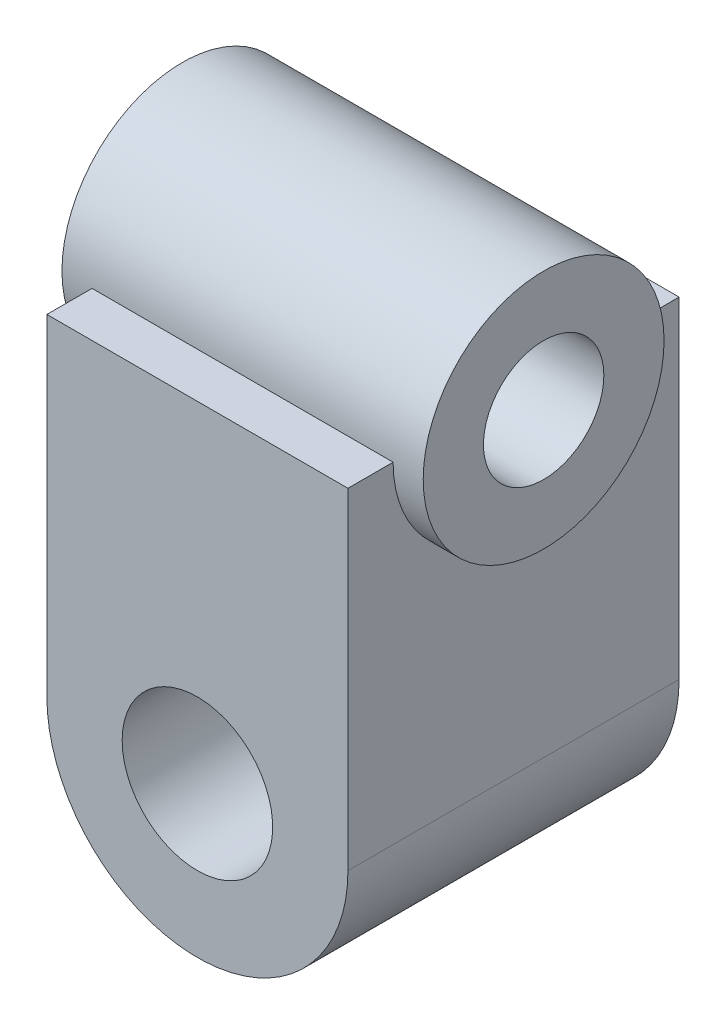
from build123d import *

# Parameters (mm, degrees)
SKETCH1_R                  = 31.75
BOSS_EXTRUDE1_DEPTH        = 34.925
SKETCH3_R                  = 25.4
BOSS_EXTRUDE2_DEPTH        = 38.1
F_97_1_DIAMETER_HOLE1_D    = 25.4
F_97_1_25_DIAMETER_HOLE1_D = 31.75


with BuildPart() as part:
    # Sketch1 → Boss-Extrude1 (new body, symmetric)
    with BuildSketch(Plane.XY):
        with BuildLine():
            ThreePointArc((-31.75, 0), (0, 31.75), (31.75, 0))
            Line((31.75, 0), (31.75, 69.85))
            Line((31.75, 69.85), (-31.75, 69.85))
            Line((-31.75, 69.85), (-31.75, 0))
        make_face()
        Circle(SKETCH1_R)
    extrude(amount=BOSS_EXTRUDE1_DEPTH, both=True)

    # Sketch3 → Boss-Extrude2 (add, symmetric)
    with BuildSketch(Plane(origin=(0, 0, 0), x_dir=(0, 0, -1), z_dir=(1, 0, 0))):
        with Locations((0, 69.85)):
            Circle(SKETCH3_R)
    extrude(amount=BOSS_EXTRUDE2_DEPTH, both=True)

    # #97 (1) Diameter Hole1 (through all)
    with Locations(Plane(origin=(38.1, 0, 0), x_dir=(0, 0, -1), z_dir=(1, 0, 0))):
        with Locations((0, 69.85)):
            Hole(F_97_1_DIAMETER_HOLE1_D / 2)

    # #97 (1.25) Diameter Hole1 (through all)
    with Locations(Plane(origin=(0, 0, -34.925), x_dir=(-1, 0, 0), z_dir=(0, 0, -1))):
        with Locations((0, 0)):
            Hole(F_97_1_25_DIAMETER_HOLE1_D / 2)


solid = part.part
